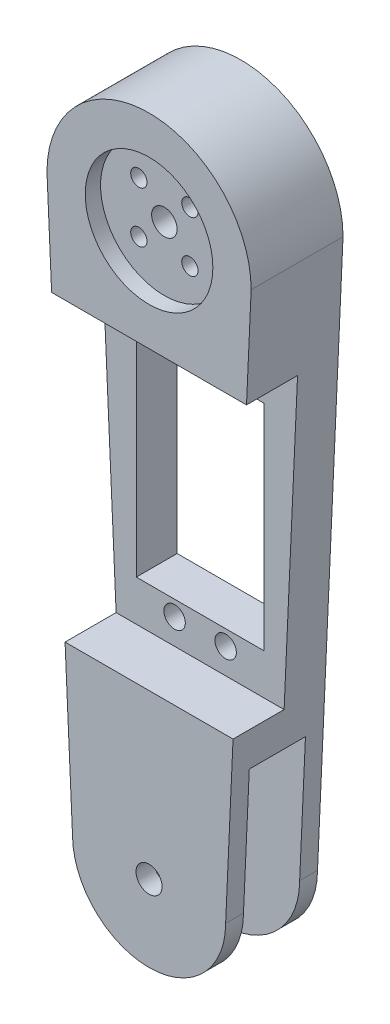
from build123d import *

# Parameters (mm, degrees)
SKETCH1_R               = 2.55
BOSS_EXTRUDE1_DEPTH     = 18
SKETCH2_R               = 12.5
CUT_EXTRUDE1_DEPTH      = 3
SKETCH3_R               = 12.5
CUT_EXTRUDE2_DEPTH      = 3
SKETCH4_R               = 2.5
SKETCH4_R_2             = 1.6
CUT_EXTRUDE3_DEPTH      = 16
SKETCH5_W               = 11
SKETCH5_H               = 40
CUT_EXTRUDE4_DEPTH      = 21
CUT_EXTRUDE4_DEPTH_BACK = 21
SKETCH7_W               = 40
SKETCH7_H               = 58
CUT_EXTRUDE5_DEPTH      = 10
SKETCH8_R               = 2.1
SKETCH8_W               = 25
SKETCH8_H               = 42
CUT_EXTRUDE6_DEPTH      = 9


with BuildPart() as part:
    # Sketch1 → Boss-Extrude1 (new body)
    with BuildSketch(Plane.XY):
        with BuildLine():
            ThreePointArc((20, 110), (0, 130), (-20, 110))
            Line((-20, 110), (-15, 0))
            ThreePointArc((-15, 0), (0, -15), (15, 0))
            Line((15, 0), (20, 110))
        make_face()
        Circle(SKETCH1_R, mode=Mode.SUBTRACT)
    extrude(amount=BOSS_EXTRUDE1_DEPTH)

    # Sketch2 → Cut-Extrude1 (cut)
    with BuildSketch(Plane.XY.offset(18)):
        with Locations((0, 110)):
            Circle(SKETCH2_R)
    extrude(amount=-CUT_EXTRUDE1_DEPTH, mode=Mode.SUBTRACT)

    # Sketch3 → Cut-Extrude2 (cut)
    with BuildSketch(Plane(origin=(0, 0, 0), x_dir=(-1, 0, 0), z_dir=(0, 0, -1))):
        with Locations((0, 110)):
            Circle(SKETCH3_R)
    extrude(amount=-CUT_EXTRUDE2_DEPTH, mode=Mode.SUBTRACT)

    # Sketch4 → Cut-Extrude3 (cut, through all)
    with BuildSketch(Plane.XY.offset(15)):
        with Locations((0, 110)):
            Circle(SKETCH4_R)
        with Locations((-5, 115)):
            Circle(SKETCH4_R_2)
        with Locations((-5, 105)):
            Circle(SKETCH4_R_2)
        with Locations((5, 105)):
            Circle(SKETCH4_R_2)
        with Locations((5, 115)):
            Circle(SKETCH4_R_2)
    extrude(amount=-CUT_EXTRUDE3_DEPTH, mode=Mode.SUBTRACT)

    # Sketch5 → Cut-Extrude4 (cut, two sides)
    with BuildSketch(Plane(origin=(0, 0, 0), x_dir=(0, 0, -1), z_dir=(1, 0, 0))) as cut_extrude4_sk:
        with Locations((-9, 5)):
            Rectangle(SKETCH5_W, SKETCH5_H)
    extrude(amount=CUT_EXTRUDE4_DEPTH, mode=Mode.SUBTRACT)
    extrude(cut_extrude4_sk.sketch, amount=-CUT_EXTRUDE4_DEPTH_BACK, mode=Mode.SUBTRACT)

    # Sketch7 → Cut-Extrude5 (cut)
    with BuildSketch(Plane.XY.offset(18)):
        with Locations((0, 61)):
            Rectangle(SKETCH7_W, SKETCH7_H)
    extrude(amount=-CUT_EXTRUDE5_DEPTH, mode=Mode.SUBTRACT)

    # Sketch8 → Cut-Extrude6 (cut, through all)
    with BuildSketch(Plane.XY.offset(8)):
        with Locations((-5, 85)):
            Circle(SKETCH8_R)
        with Locations((5, 85)):
            Circle(SKETCH8_R)
        with Locations((5, 37)):
            Circle(SKETCH8_R)
        with Locations((-5, 37)):
            Circle(SKETCH8_R)
        with Locations((0, 61)):
            Rectangle(SKETCH8_W, SKETCH8_H)
    extrude(amount=-CUT_EXTRUDE6_DEPTH, mode=Mode.SUBTRACT)


solid = part.part
